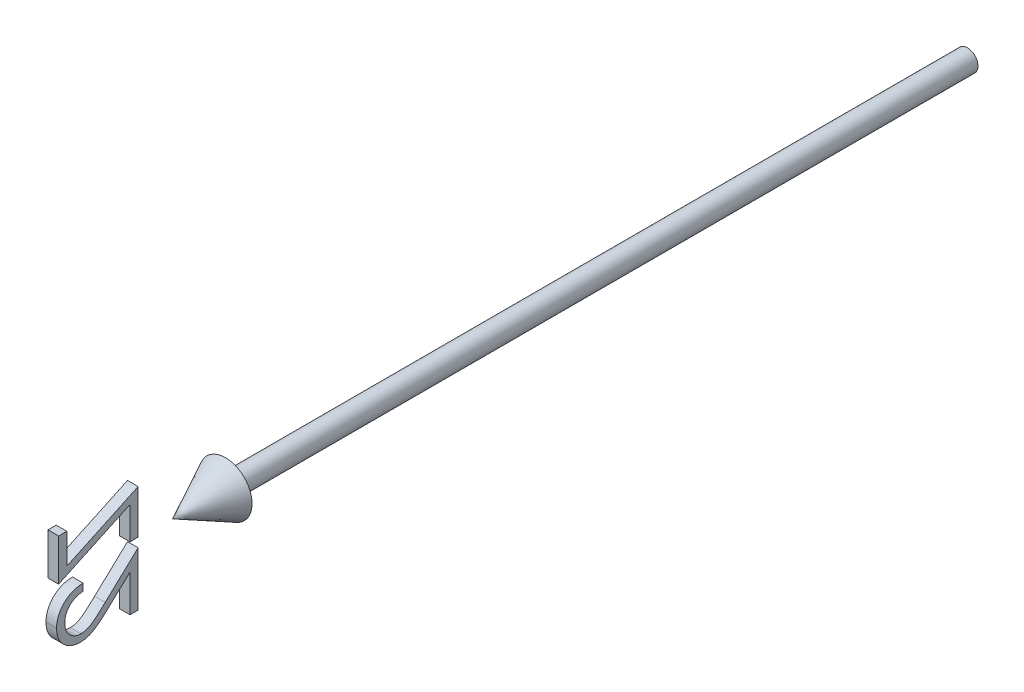
from build123d import *

# Parameters (mm, degrees)
BOSS_EXTRUDE1_DEPTH        = 1
BOSS_EXTRUDE1_DEPTH_BACK   = 1
BOSS_EXTRUDE1_2_DEPTH      = 1
BOSS_EXTRUDE1_2_DEPTH_BACK = 1


with BuildPart() as part:
    # Sketch2 → Revolve1 (revolve)
    with BuildSketch(Plane(origin=(0, 0, 0), x_dir=(1, 0, 0), z_dir=(0, 1, 0))):
        Polygon((0, -150), (5, -140), (2, -140), (2, 0), (0, 0), align=None)
    revolve(axis=Axis((0, 0, -41.949952025), (0, 0, 1)))


with BuildPart() as body_2:
    # Sketch3 → Boss-Extrude1 (new, two sides: drawn at the far end of the back side and taken through both)
    with BuildSketch(Plane(origin=(0, 0, 0), x_dir=(0, -1, 0), z_dir=(1, 0, 0)).offset(-BOSS_EXTRUDE1_DEPTH_BACK)):
        Polygon((-8.958586521, -170.961538462), (-8.958586521, -172.5), (-1.073971137, -172.5), (-7.366038444, -159.038461538), (-1.266278829, -159.038461538), (-1.266278829, -157.5), (-9.535509598, -157.5), (-3.243442291, -170.961538462), align=None)
    extrude(amount=BOSS_EXTRUDE1_DEPTH + BOSS_EXTRUDE1_DEPTH_BACK)


with BuildPart() as body_3:
    # Sketch3 → Boss-Extrude1 2 (new, two sides: drawn at the far end of the back side and taken through both)
    with BuildSketch(Plane(origin=(0, 0, 0), x_dir=(0, -1, 0), z_dir=(1, 0, 0)).offset(-BOSS_EXTRUDE1_2_DEPTH_BACK)):
        with BuildLine():
            Line((2.387567325, -167.884615385), (1.041413479, -167.884615385))
            add(Edge.make_bspline(
                [(1.041413479, -167.884615385), (1.050185498, -168.063205784), (1.067413511, -168.413952575), (1.14812731, -168.925328289), (1.263511735, -169.414179653), (1.427038382, -169.876315664), (1.628979502, -170.317256926), (1.876213873, -170.731148249), (2.163470857, -171.122097454), (2.490223471, -171.482702577), (2.844780172, -171.812340745), (3.225016614, -172.100012522), (3.627024685, -172.340286171), (4.047317539, -172.542241714), (4.490755987, -172.693649809), (4.953101254, -172.806041475), (5.436443094, -172.873650782), (5.765757104, -172.880918932), (5.933240402, -172.884615385)],
                knots=[0, 0, 0, 0, 1.100776268, 2.161895295, 3.184016182, 4.190939212, 5.176500551, 6.166955529, 7.155448256, 8.160289653, 9.16017456, 10.133824356, 11.091467644, 12.04088621, 13.000931625, 13.972173743, 14.968683325, 16, 16, 16, 16], degree=3))
            add(Edge.make_bspline(
                [(5.933240402, -172.884615385), (6.097729437, -172.880796104), (6.420944515, -172.873291355), (6.892475118, -172.807873473), (7.3424284, -172.707626401), (7.765705045, -172.559076032), (8.166649061, -172.372677813), (8.540296096, -172.140867206), (8.895681325, -171.87461271), (9.21536306, -171.560552476), (9.509029299, -171.225449413), (9.762151841, -170.867562158), (9.980142966, -170.497495718), (10.158561893, -170.112359334), (10.293811374, -169.710898815), (10.394018278, -169.2969631), (10.451301959, -168.865775091), (10.460045253, -168.573881456), (10.464490402, -168.425480769)],
                knots=[0, 0, 0, 0, 1.111674182, 2.184400057, 3.212814286, 4.223731311, 5.211378316, 6.196328225, 7.191884489, 8.207283132, 9.220262353, 10.201199469, 11.166417575, 12.120932471, 13.06540007, 14.026332106, 14.996573967, 16, 16, 16, 16], degree=3))
            add(Edge.make_bspline(
                [(10.464490402, -168.425480769), (10.457233447, -168.216561568), (10.442846886, -167.802389402), (10.319786944, -167.193752958), (10.127581249, -166.604071894), (9.896184514, -166.129467281), (9.662685279, -165.747074226), (9.452479023, -165.43207523), (9.204998347, -165.092995253), (8.922357616, -164.728461871), (8.599689356, -164.343248958), (8.245376446, -163.929497135), (7.850268631, -163.494856958), (7.573203067, -163.197798463), (7.429634633, -163.043870192)],
                knots=[0, 0, 0, 0, 1.184416499, 2.348048165, 3.509039915, 4.696071444, 5.333504901, 6.05069495, 6.844171097, 7.714965912, 8.667477798, 9.695072654, 10.805644396, 12, 12, 12, 12], degree=3))
            Line((7.429634633, -163.043870192), (3.676629825, -159.038461538))
            Line((3.676629825, -159.038461538), (10.656798094, -159.038461538))
            Line((10.656798094, -159.038461538), (10.656798094, -157.5))
            Line((10.656798094, -157.5), (0.464490402, -157.5))
            Line((0.464490402, -157.5), (6.281798094, -163.707932692))
            add(Edge.make_bspline(
                [(6.281798094, -163.707932692), (6.423441922, -163.855774514), (6.695510728, -164.139748395), (7.080161273, -164.554467176), (7.426195028, -164.938755758), (7.733841533, -165.294317016), (8.003353921, -165.619135251), (8.233869872, -165.915755986), (8.426408224, -166.181633708), (8.630458754, -166.493975739), (8.825034475, -166.87577944), (8.996046625, -167.340016559), (9.099575053, -167.818969101), (9.112057685, -168.142533031), (9.118336556, -168.305288462)],
                knots=[0, 0, 0, 0, 1.329530082, 2.553755191, 3.672934919, 4.687409497, 5.60679272, 6.413407421, 7.126401618, 7.737995624, 8.834647426, 9.90044882, 10.943907757, 12, 12, 12, 12], degree=3))
            add(Edge.make_bspline(
                [(9.118336556, -168.305288462), (9.115639933, -168.407648622), (9.110325407, -168.609380842), (9.06253371, -168.904957531), (8.992318222, -169.191181234), (8.884094464, -169.464512999), (8.754067603, -169.730328736), (8.5879487, -169.980546816), (8.398118417, -170.223696572), (8.1779246, -170.451440602), (7.936192702, -170.660089498), (7.68078048, -170.844903048), (7.410567913, -170.999357413), (7.126681095, -171.125972124), (6.829914955, -171.225295262), (6.519694576, -171.294117725), (6.196877375, -171.337328376), (5.976448106, -171.343174826), (5.864129825, -171.346153846)],
                knots=[0, 0, 0, 0, 0.991504627, 1.954065223, 2.895985987, 3.842598665, 4.797835564, 5.759220273, 6.74786863, 7.784730864, 8.824135544, 9.839918996, 10.835834653, 11.835434876, 12.84861661, 13.863796685, 14.911511676, 16, 16, 16, 16], degree=3))
            add(Edge.make_bspline(
                [(5.864129825, -171.346153846), (5.746796292, -171.343211269), (5.516372606, -171.337432534), (5.178786616, -171.293634499), (4.854486528, -171.227304609), (4.548469717, -171.121707967), (4.254331796, -170.998120893), (3.97957637, -170.838097372), (3.716485215, -170.655245751), (3.47034786, -170.442052376), (3.246169917, -170.201389167), (3.042233236, -169.939431517), (2.869435664, -169.651535448), (2.716045003, -169.344609108), (2.59873143, -169.010219964), (2.498436733, -168.656545911), (2.42558412, -168.278540852), (2.400450063, -168.018104774), (2.387567325, -167.884615385)],
                knots=[0, 0, 0, 0, 1.031072318, 2.024855787, 2.988461151, 3.935103592, 4.865765533, 5.788564469, 6.724086513, 7.67908574, 8.64457978, 9.611397706, 10.591395687, 11.591555111, 12.622101007, 13.700900657, 14.821571223, 16, 16, 16, 16], degree=3))
        make_face()
    extrude(amount=BOSS_EXTRUDE1_2_DEPTH + BOSS_EXTRUDE1_2_DEPTH_BACK)


solid = Compound([part.part, body_2.part, body_3.part])
